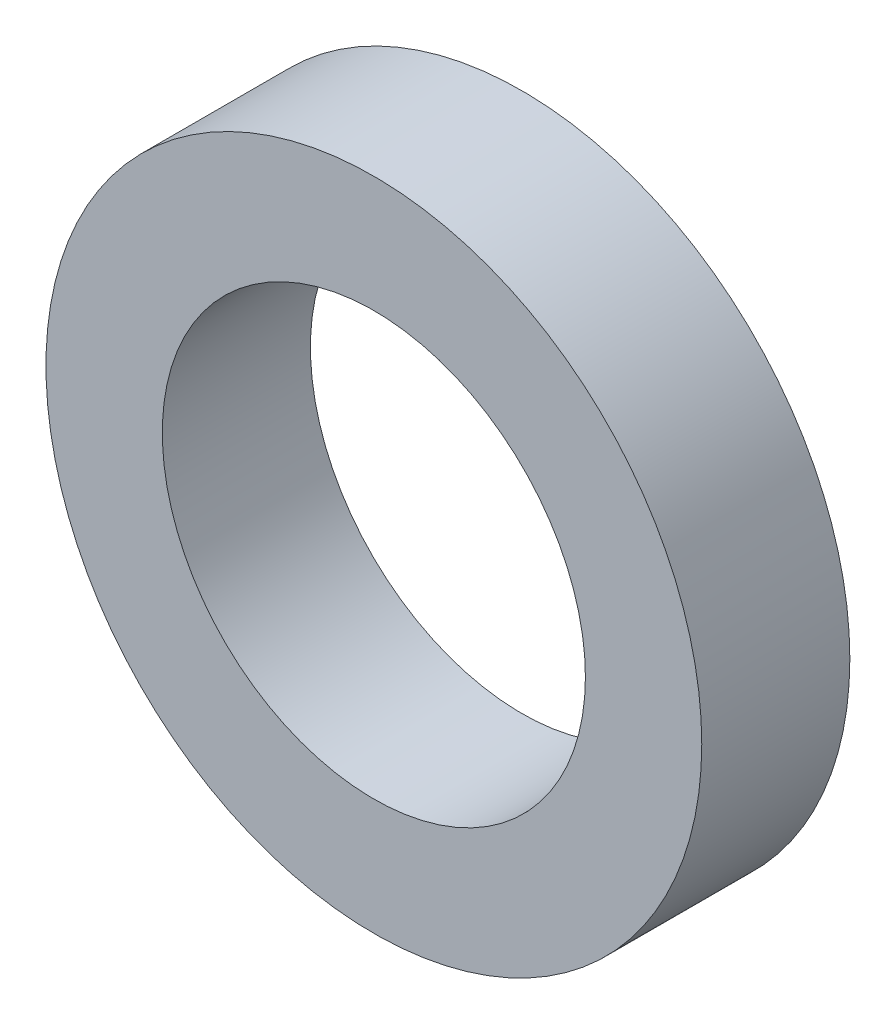
from build123d import *

# Parameters (mm, degrees)
SKETCH_1_R          = 7.75
EXTRUDE_1_DEPTH     = 1.75
SKETCH_2_R          = 5
CUT_EXTRUDE_1_DEPTH = 1.75


with BuildPart() as part:
    # 草图1 → 凸台-拉伸1 (new body, symmetric)
    with BuildSketch(Plane.XY):
        Circle(SKETCH_1_R)
    extrude(amount=EXTRUDE_1_DEPTH, both=True)

    # 草图2 → 切除-拉伸1 (cut, symmetric)
    with BuildSketch(Plane.XY):
        Circle(SKETCH_2_R)
    extrude(amount=CUT_EXTRUDE_1_DEPTH, both=True, mode=Mode.SUBTRACT)


solid = part.part
